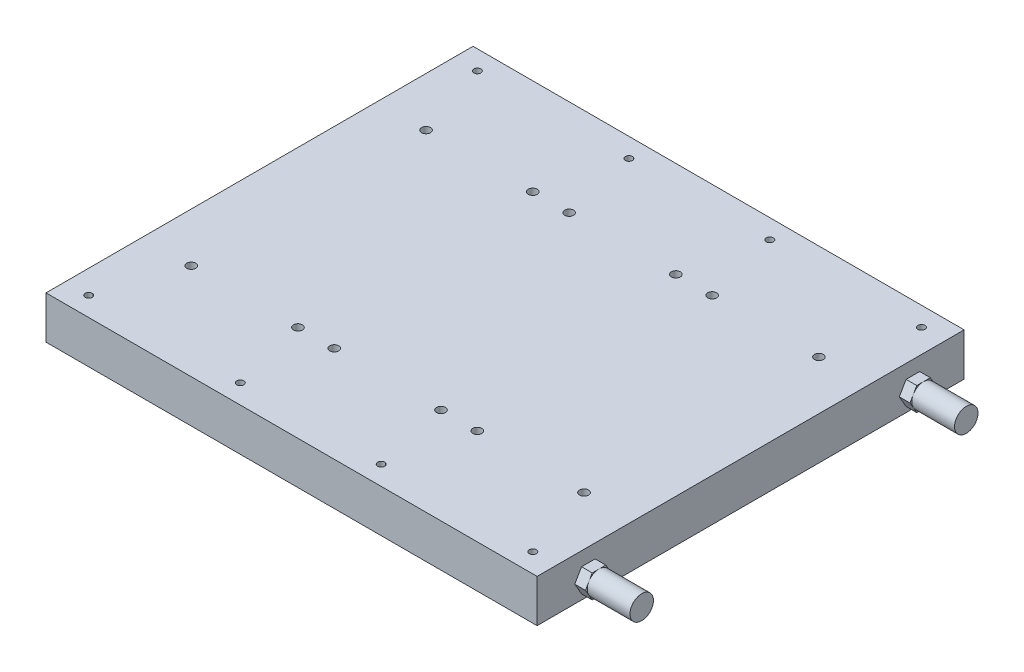
from build123d import *

# Parameters (mm, degrees)
SZKIC1_W                    = 230
SZKIC1_H                    = 200
DODANIE_WYCI_GNI_CIE1_DEPTH = 20
OTW_R_GWINTOWANY_M52_D      = 4.2
OTW_R_GWINTOWANY_M52_DEPTH  = 14
OTW_R_GWINTOWANY_M52_TIP    = 1.2618073
OTW_R_GWINTOWANY_M41_D      = 3.3
OTW_R_GWINTOWANY_M41_DEPTH  = 11.5
OTW_R_GWINTOWANY_M41_TIP    = 0.991420021
DODANIE_WYCI_GNI_CIE2_DEPTH = 5
SZKIC10_R                   = 5.5
DODANIE_WYCI_GNI_CIE3_DEPTH = 20


with BuildPart() as part:
    # Szkic1 → Dodanie-wyciągnięcie1 (new body)
    with BuildSketch(Plane(origin=(0, 0, 0), x_dir=(1, 0, 0), z_dir=(0, 1, 0))):
        Rectangle(SZKIC1_W, SZKIC1_H)
    extrude(amount=DODANIE_WYCI_GNI_CIE1_DEPTH)

    # Otwór gwintowany M52
    with Locations(Plane(origin=(-92, 20, -55), x_dir=(0, 0, 1), z_dir=(0, 1, 0))):
        with Locations((0, 0), (0, 50), (0, 67), (0, 117), (110, 117), (110, 67), (110, 50), (110, 0), (110, 134), (0, 134), (0, 184), (110, 184)):
            Hole(OTW_R_GWINTOWANY_M52_D / 2, depth=OTW_R_GWINTOWANY_M52_DEPTH)
            with Locations((0, 0, -(OTW_R_GWINTOWANY_M52_DEPTH + OTW_R_GWINTOWANY_M52_TIP / 2))):  # 118° drill point
                Cone(0, OTW_R_GWINTOWANY_M52_D / 2, OTW_R_GWINTOWANY_M52_TIP, mode=Mode.SUBTRACT)

    # Otwór gwintowany M41
    with Locations(Plane(origin=(-104, 20, -91), x_dir=(0, 0, 1), z_dir=(0, 1, 0))):
        with Locations((0, 0), (0, 71), (0, 137), (0, 208), (182, 208), (182, 137), (182, 71), (182, 0)):
            Hole(OTW_R_GWINTOWANY_M41_D / 2, depth=OTW_R_GWINTOWANY_M41_DEPTH)
            with Locations((0, 0, -(OTW_R_GWINTOWANY_M41_DEPTH + OTW_R_GWINTOWANY_M41_TIP / 2))):  # 118° drill point
                Cone(0, OTW_R_GWINTOWANY_M41_D / 2, OTW_R_GWINTOWANY_M41_TIP, mode=Mode.SUBTRACT)

    # Szkic9 → Dodanie-wyciągnięcie2 (add)
    with BuildSketch(Plane(origin=(115, 0, 0), x_dir=(0, 0, -1), z_dir=(1, 0, 0))):
        Polygon((-69.649147039, 8), (-72.824573519, 13.5), (-79.175426481, 13.5), (-82.350852961, 8), (-79.175426481, 2.5), (-72.824573519, 2.5), align=None)
        Polygon((69.649147039, 8), (72.824573519, 2.5), (79.175426481, 2.5), (82.350852961, 8), (79.175426481, 13.5), (72.824573519, 13.5), align=None)
    extrude(amount=DODANIE_WYCI_GNI_CIE2_DEPTH)

    # Szkic10 → Dodanie-wyciągnięcie3 (add)
    with BuildSketch(Plane(origin=(120, 0, 0), x_dir=(0, 0, -1), z_dir=(1, 0, 0))):
        with Locations((76, 8)):
            Circle(SZKIC10_R)
        with Locations((-76, 8)):
            Circle(SZKIC10_R)
    extrude(amount=DODANIE_WYCI_GNI_CIE3_DEPTH)


solid = part.part
